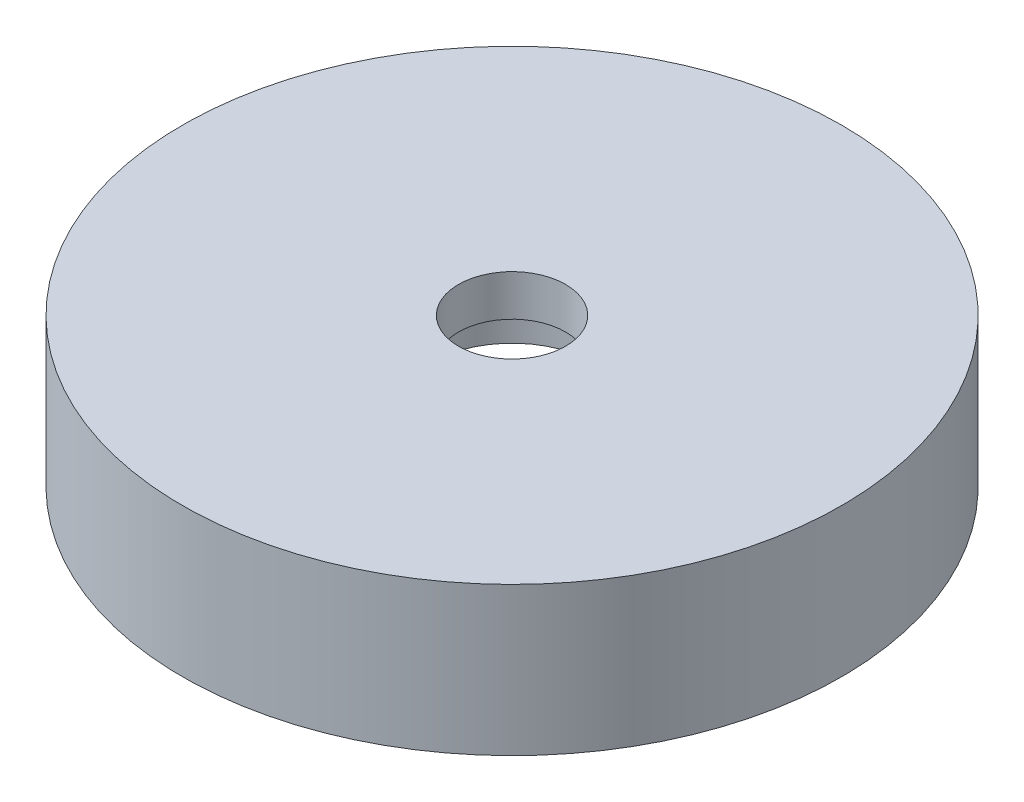
from build123d import *


with BuildPart() as part:
    # Esboço1 → Revolução1 (revolve)
    with BuildSketch(Plane.XY):
        Polygon((3.25, 14), (3.25, 11.5), (5, 11.5), (5, 9), (17.5, 9), (17.5, 5), (20, 5), (20, 14), align=None)
    revolve(axis=Axis((0, 0, 0), (0, 1, 0)))


solid = part.part
